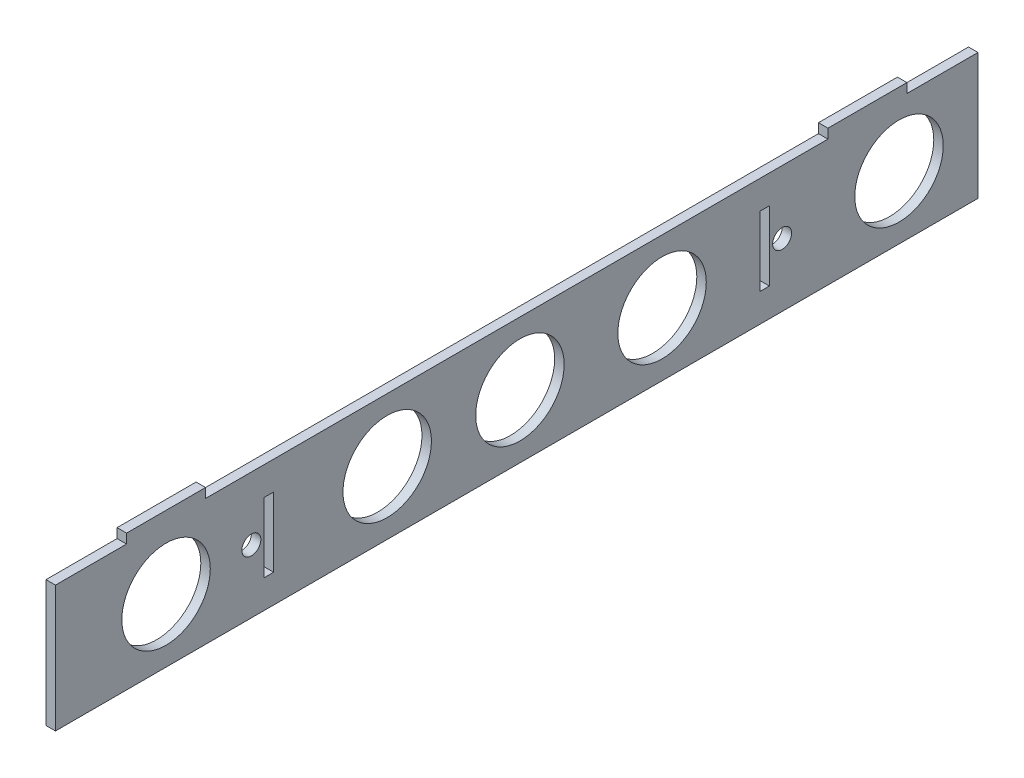
from build123d import *

# Parameters (mm, degrees)
SKETCH3_W           = 292
SKETCH3_H           = 40
SKETCH3_W_2         = 3
SKETCH3_H_2         = 22
SKETCH3_W_3         = 25
SKETCH3_H_3         = 3
BOSS_EXTRUDE2_DEPTH = 3
SKETCH5_R           = 14
CUT_EXTRUDE1_DEPTH  = 10
SKETCH6_R           = 3
CUT_EXTRUDE2_DEPTH  = 10


with BuildPart() as part:
    # Sketch3 → Boss-Extrude2 (new body)
    with BuildSketch(Plane(origin=(0, 0, 0), x_dir=(0, 0, -1), z_dir=(1, 0, 0))):
        with Locations((146, -20)):
            Rectangle(SKETCH3_W, SKETCH3_H)
        with Locations((67.54, -20)):
            Rectangle(SKETCH3_W_2, SKETCH3_H_2, mode=Mode.SUBTRACT)
        with Locations((224.46, -20)):
            Rectangle(SKETCH3_W_2, SKETCH3_H_2, mode=Mode.SUBTRACT)
        with Locations((35, 1.5)):
            Rectangle(SKETCH3_W_3, SKETCH3_H_3)
        with Locations((257, 1.5)):
            Rectangle(SKETCH3_W_3, SKETCH3_H_3)
    extrude(amount=BOSS_EXTRUDE2_DEPTH)

    # Sketch5 → Cut-Extrude1 (cut)
    with BuildSketch(Plane(origin=(3, 0, 0), x_dir=(0, 0, -1), z_dir=(1, 0, 0))):
        with Locations((35, -20)):
            Circle(SKETCH5_R)
        with Locations((105, -20)):
            Circle(SKETCH5_R)
        with Locations((147, -20)):
            Circle(SKETCH5_R)
        with Locations((192, -20)):
            Circle(SKETCH5_R)
        with Locations((267, -20)):
            Circle(SKETCH5_R)
    extrude(amount=-CUT_EXTRUDE1_DEPTH, mode=Mode.SUBTRACT)

    # Sketch6 → Cut-Extrude2 (cut)
    with BuildSketch(Plane(origin=(3, 0, 0), x_dir=(0, 0, -1), z_dir=(1, 0, 0))):
        with Locations((62, -20)):
            Circle(SKETCH6_R)
        with Locations((230, -20)):
            Circle(SKETCH6_R)
    extrude(amount=-CUT_EXTRUDE2_DEPTH, mode=Mode.SUBTRACT)


solid = part.part
